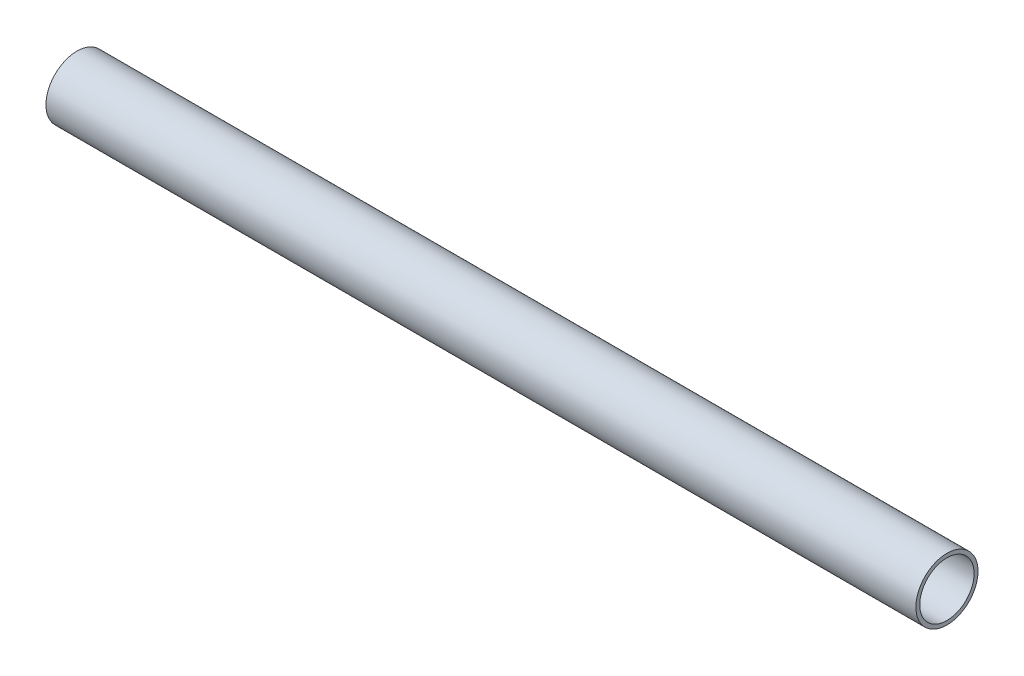
from build123d import *

# Parameters (mm, degrees)
SKETCH1_R           = 12.7
SKETCH1_R_2         = 11.1125
BOSS_EXTRUDE1_DEPTH = 355.6


with BuildPart() as part:
    # Sketch1 → Boss-Extrude1 (new body)
    with BuildSketch(Plane(origin=(0, 0, 0), x_dir=(0, 0, -1), z_dir=(1, 0, 0))):
        Circle(SKETCH1_R)
        Circle(SKETCH1_R_2, mode=Mode.SUBTRACT)
    extrude(amount=BOSS_EXTRUDE1_DEPTH)


solid = part.part
